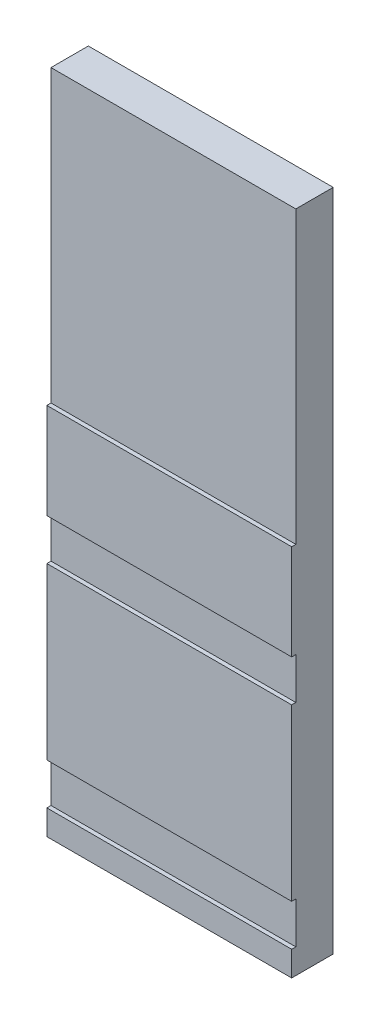
from build123d import *

# Parameters (mm, degrees)
ESQUISSE1_W          = 59
ESQUISSE1_H          = 23
BOSS_EXTRU_4_DEPTH   = 10
ESQUISSE1_H_2        = 41
BOSS_EXTRU_4_2_DEPTH = 10
ESQUISSE1_H_3        = 6
BOSS_EXTRU_4_3_DEPTH = 10
ESQUISSE1_6_W        = 59
ESQUISSE1_6_H        = 70
ESQUISSE1_6_H_2      = 10
BOSS_EXTRU_5_DEPTH   = 9


with BuildPart() as part:
    # Esquisse1 → Boss.-Extru.4 (new body)
    with BuildSketch(Plane.XY):
        with Locations((-16.034238867, -28.643003421)):
            Rectangle(ESQUISSE1_W, ESQUISSE1_H)
    extrude(amount=BOSS_EXTRU_4_DEPTH)



with BuildPart() as body_2:
    # Esquisse1 → Boss.-Extru.4 2 (new body)
    with BuildSketch(Plane.XY):
        with Locations((-16.034238867, -70.643003421)):
            Rectangle(ESQUISSE1_W, ESQUISSE1_H_2)
    extrude(amount=BOSS_EXTRU_4_2_DEPTH)


with BuildPart() as body_3:
    # Esquisse1 → Boss.-Extru.4 3 (new body)
    with BuildSketch(Plane.XY):
        with Locations((-16.034238867, -104.143003421)):
            Rectangle(ESQUISSE1_W, ESQUISSE1_H_3)
    extrude(amount=BOSS_EXTRU_4_3_DEPTH)


with BuildPart() as part_1:
    add(part.part)

    add(body_2.part)  # Boss.-Extru.5 merges body 2

    add(body_3.part)  # Boss.-Extru.5 merges body 3
    # Esquisse1_6 → Boss.-Extru.5 (add)
    with BuildSketch(Plane.XY):
        with Locations((-16.034238867, 17.856996579)):
            Rectangle(ESQUISSE1_6_W, ESQUISSE1_6_H)
        with Locations((-16.034238867, -45.143003421)):
            Rectangle(ESQUISSE1_6_W, ESQUISSE1_6_H_2)
        with Locations((-16.034238867, -96.143003421)):
            Rectangle(ESQUISSE1_6_W, ESQUISSE1_6_H_2)
    extrude(amount=BOSS_EXTRU_5_DEPTH)


solid = part_1.part
